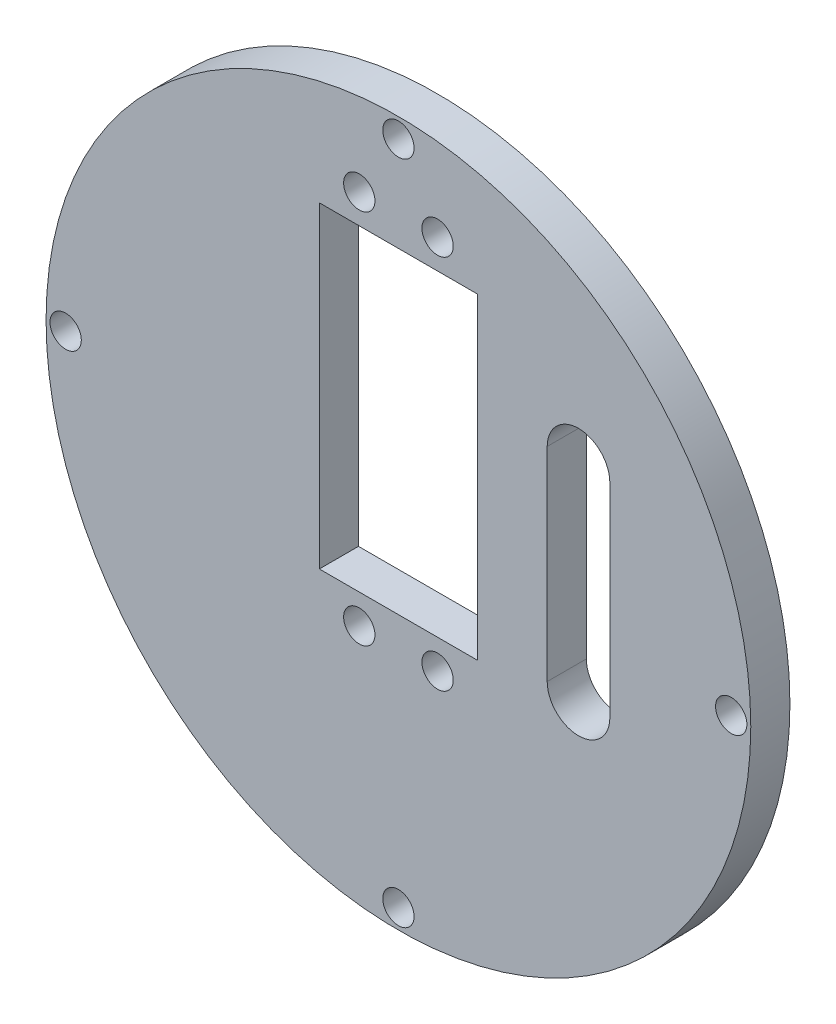
from build123d import *

# Parameters (mm, degrees)
SKETCH1_R           = 45
SKETCH1_R_2         = 2
SKETCH1_W           = 20.2
SKETCH1_H           = 40.5
BOSS_EXTRUDE1_DEPTH = 5
CUT_EXTRUDE1_DEPTH  = 10


with BuildPart() as part:
    # Sketch1 → Boss-Extrude1 (new body)
    with BuildSketch(Plane.XY):
        Circle(SKETCH1_R)
        with Locations((0, 42.5)):
            Circle(SKETCH1_R_2, mode=Mode.SUBTRACT)
        with Locations((-42.5, 0)):
            Circle(SKETCH1_R_2, mode=Mode.SUBTRACT)
        with Locations((0, -42.5)):
            Circle(SKETCH1_R_2, mode=Mode.SUBTRACT)
        with Locations((42.5, 0)):
            Circle(SKETCH1_R_2, mode=Mode.SUBTRACT)
        with Locations((-5, -13.85)):
            Circle(SKETCH1_R_2, mode=Mode.SUBTRACT)
        with Locations((5, -13.85)):
            Circle(SKETCH1_R_2, mode=Mode.SUBTRACT)
        with Locations((5, 34.15)):
            Circle(SKETCH1_R_2, mode=Mode.SUBTRACT)
        with Locations((-5, 34.15)):
            Circle(SKETCH1_R_2, mode=Mode.SUBTRACT)
        with Locations((0, 10.15)):
            Rectangle(SKETCH1_W, SKETCH1_H, mode=Mode.SUBTRACT)
    extrude(amount=BOSS_EXTRUDE1_DEPTH)

    # Sketch2 → Cut-Extrude1 (cut)
    with BuildSketch(Plane(origin=(0, 0, 0), x_dir=(-1, 0, 0), z_dir=(0, 0, -1))):
        with BuildLine():
            Line((-19, 18), (-19, -8))
            ThreePointArc((-19, -8), (-23, -12), (-27, -8))
            Line((-27, -8), (-27, 18))
            ThreePointArc((-27, 18), (-23, 22), (-19, 18))
        make_face()
    extrude(amount=-CUT_EXTRUDE1_DEPTH, mode=Mode.SUBTRACT)


solid = part.part
